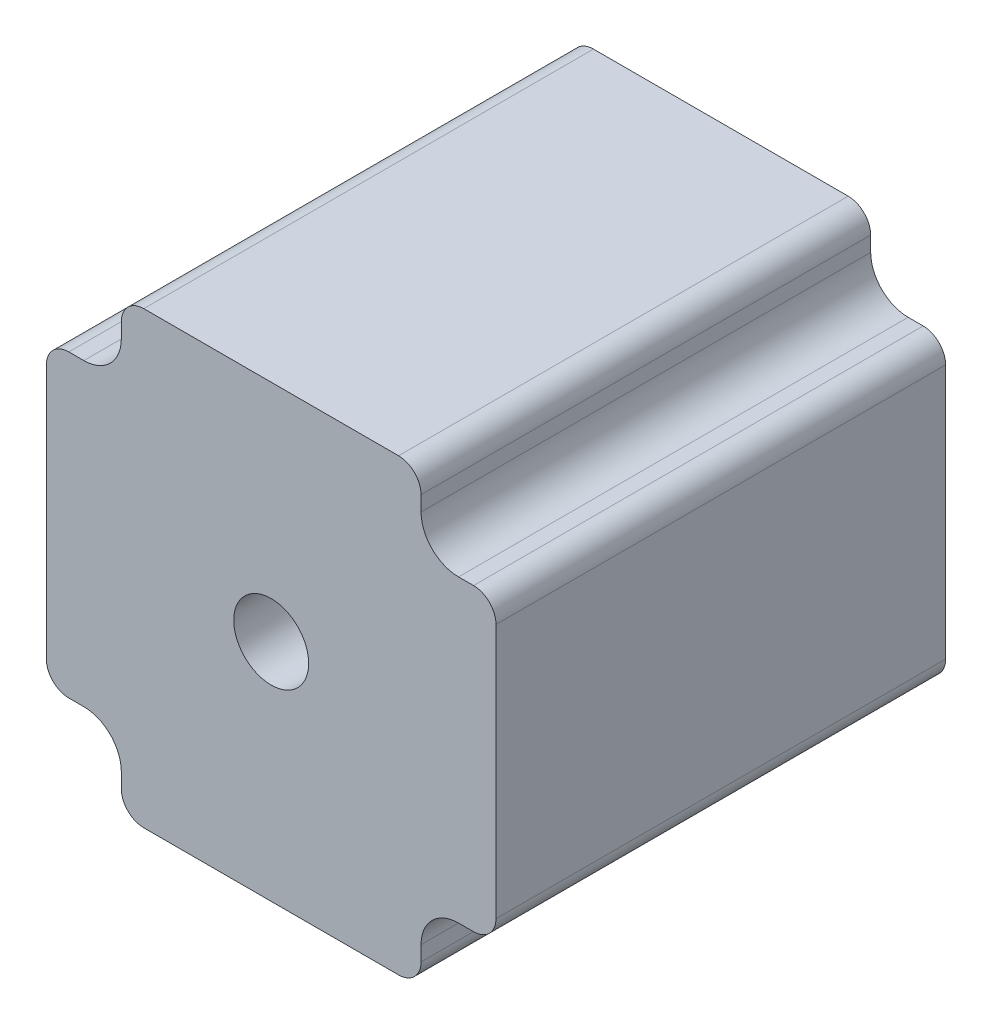
from build123d import *

# Parameters (mm, degrees)
Y_KSEKLIK_EKSTR_ZYON1_DEPTH = 60
IZIM2_R                     = 5
KES_EKSTR_ZYON1_DEPTH       = 61


with BuildPart() as part:
    # Çizim1 → Yükseklik-Ekstrüzyon1 (new body)
    with BuildSketch(Plane.XY):
        with BuildLine():
            Line((-45.299869289, 30.731722377), (-45.299869289, 28.731722377))
            ThreePointArc((-45.299869289, 28.731722377), (-46.764335383, 25.196188471), (-50.299869289, 23.731722377))
            Line((-50.299869289, 23.731722377), (-52.299869289, 23.731722377))
            ThreePointArc((-52.299869289, 23.731722377), (-54.421189632, 22.853042721), (-55.299869289, 20.731722377))
            Line((-55.299869289, 20.731722377), (-55.299869289, -13.268277623))
            ThreePointArc((-55.299869289, -13.268277623), (-54.421189632, -15.389597966), (-52.299869289, -16.268277623))
            Line((-52.299869289, -16.268277623), (-50.299869289, -16.268277623))
            ThreePointArc((-50.299869289, -16.268277623), (-46.764335383, -17.732743717), (-45.299869289, -21.268277623))
            Line((-45.299869289, -21.268277623), (-45.299869289, -23.268277623))
            ThreePointArc((-45.299869289, -23.268277623), (-44.421189632, -25.389597966), (-42.299869289, -26.268277623))
            Line((-42.299869289, -26.268277623), (-8.299869289, -26.268277623))
            ThreePointArc((-8.299869289, -26.268277623), (-6.178548945, -25.389597966), (-5.299869289, -23.268277623))
            Line((-5.299869289, -23.268277623), (-5.299869289, -21.268277623))
            ThreePointArc((-5.299869289, -21.268277623), (-3.835403195, -17.732743717), (-0.299869289, -16.268277623))
            Line((-0.299869289, -16.268277623), (1.700130711, -16.268277623))
            ThreePointArc((1.700130711, -16.268277623), (3.821451055, -15.389597966), (4.700130711, -13.268277623))
            Line((4.700130711, -13.268277623), (4.700130711, 20.731722377))
            ThreePointArc((4.700130711, 20.731722377), (3.821451055, 22.853042721), (1.700130711, 23.731722377))
            Line((1.700130711, 23.731722377), (-0.299869289, 23.731722377))
            ThreePointArc((-0.299869289, 23.731722377), (-3.835403195, 25.196188471), (-5.299869289, 28.731722377))
            Line((-5.299869289, 28.731722377), (-5.299869289, 30.731722377))
            ThreePointArc((-5.299869289, 30.731722377), (-6.178548945, 32.853042721), (-8.299869289, 33.731722377))
            Line((-8.299869289, 33.731722377), (-42.299869289, 33.731722377))
            ThreePointArc((-42.299869289, 33.731722377), (-44.421189632, 32.853042721), (-45.299869289, 30.731722377))
        make_face()
    extrude(amount=Y_KSEKLIK_EKSTR_ZYON1_DEPTH)

    # Çizim2 → Kes-Ekstrüzyon1 (cut, through all)
    with BuildSketch(Plane.XY.offset(60)):
        with Locations((-25.299869289, 3.731722377)):
            Circle(IZIM2_R)
    extrude(amount=-KES_EKSTR_ZYON1_DEPTH, mode=Mode.SUBTRACT)


solid = part.part
